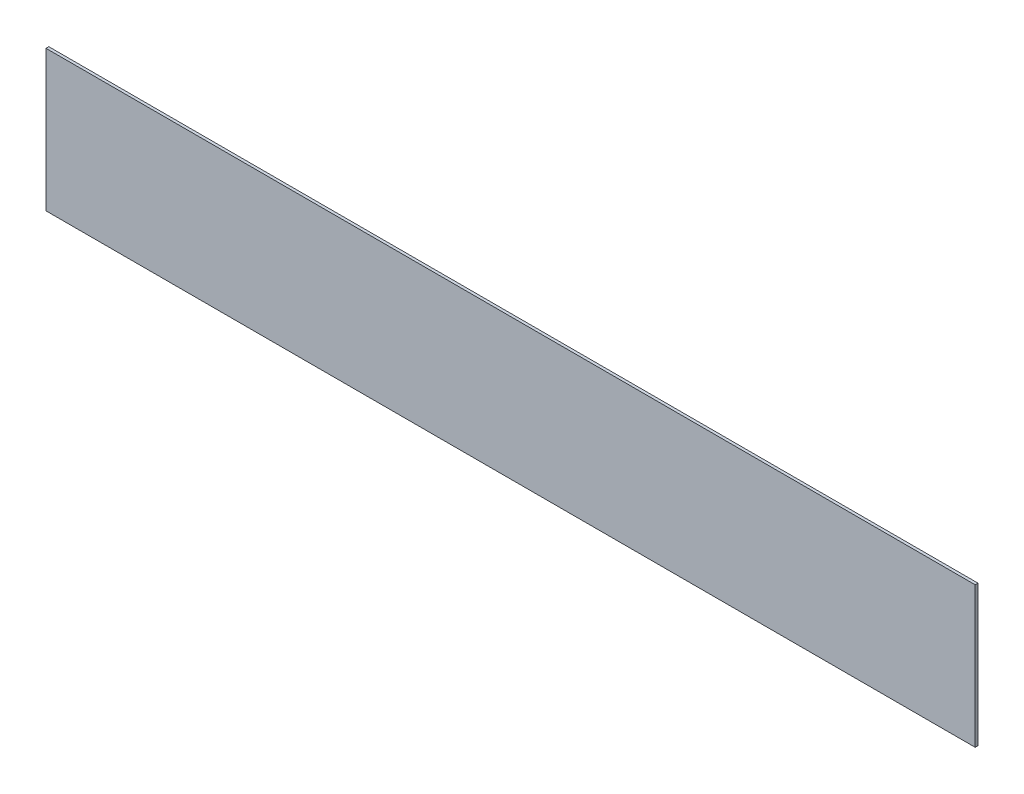
from build123d import *

# Parameters (mm, degrees)
SKETCH_1_W      = 33
SKETCH_1_H      = 5
EXTRUDE_1_DEPTH = 0.1


with BuildPart() as part:
    # 草图1 → 凸台-拉伸1 (new body)
    with BuildSketch(Plane.XY):
        Rectangle(SKETCH_1_W, SKETCH_1_H)
    extrude(amount=EXTRUDE_1_DEPTH)


solid = part.part
